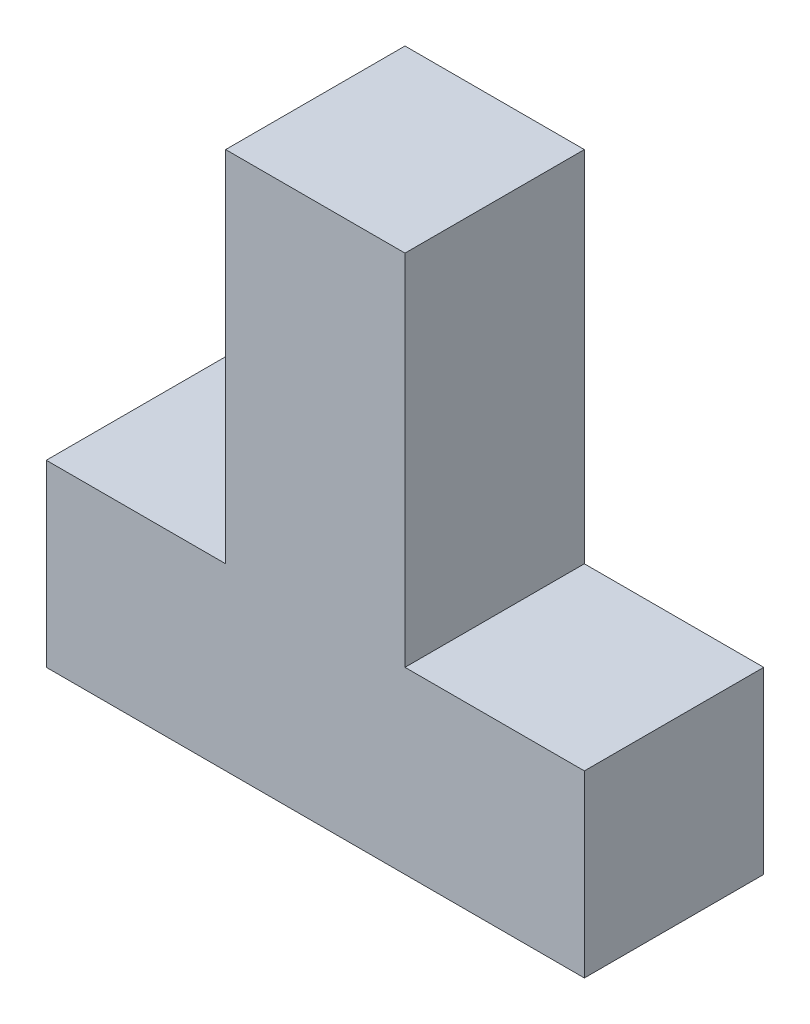
from build123d import *

# Parameters (mm, degrees)
BOSS_EXTRUDE1_DEPTH = 25.4


with BuildPart() as part:
    # Sketch1 → Boss-Extrude1 (new body)
    with BuildSketch(Plane.XY):
        Polygon((76.2, 0), (76.2, 25.4), (50.8, 25.4), (50.8, 76.2), (25.4, 76.2), (25.4, 25.4), (0, 25.4), (0, 0), align=None)
    extrude(amount=BOSS_EXTRUDE1_DEPTH)


solid = part.part
